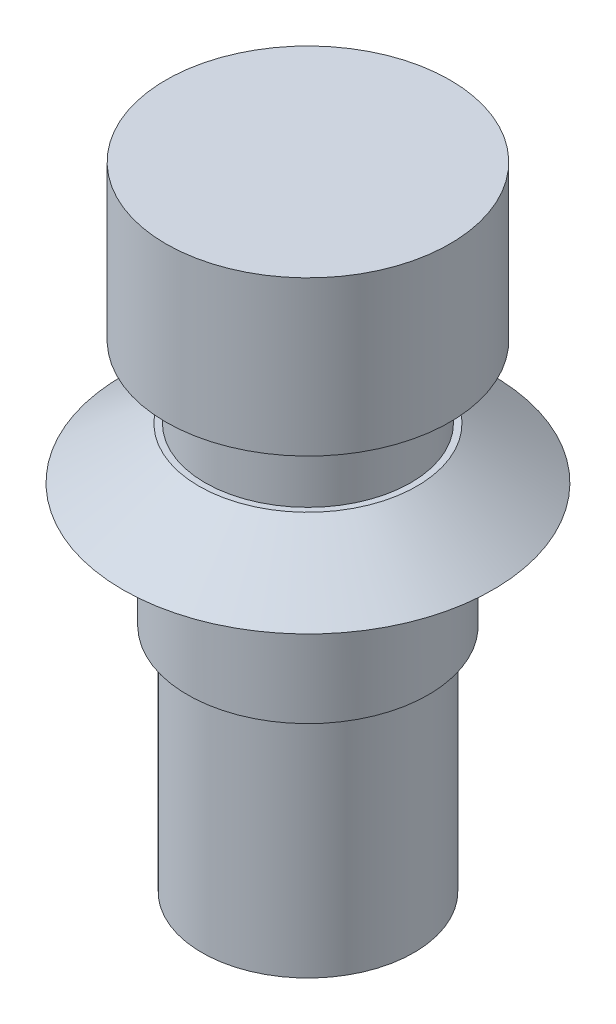
from build123d import *

# Parameters (mm, degrees)
SKETCH1_R           = 5.85
BOSS_EXTRUDE1_DEPTH = 17.2
SKETCH2_R           = 9
BOSS_EXTRUDE2_DEPTH = 2.5
BOSS_EXTRUDE2_TAPER = 56
SKETCH3_R           = 5
BOSS_EXTRUDE3_DEPTH = 3.5
SKETCH4_R           = 6.9
BOSS_EXTRUDE4_DEPTH = 7.5
SKETCH5_OUTSIDE_W   = 27.976
SKETCH5_OUTSIDE_H   = 27.976
SKETCH5_OUTSIDE_R   = 5.15
CUT_EXTRUDE1_DEPTH  = 11.2


with BuildPart() as part:
    # Sketch1 → Boss-Extrude1 (new body)
    with BuildSketch(Plane(origin=(0, 0, 0), x_dir=(1, 0, 0), z_dir=(0, 1, 0))):
        with Locations(Location((0, 0, 0), (0, 0, 270))):  # turned: the seam where the file's is
            Circle(SKETCH1_R)
    extrude(amount=BOSS_EXTRUDE1_DEPTH)

    # Sketch2 → Boss-Extrude2 (add)
    with BuildSketch(Plane(origin=(0, 17.2, 0), x_dir=(1, 0, 0), z_dir=(0, 1, 0))):
        Circle(SKETCH2_R)
    extrude(amount=BOSS_EXTRUDE2_DEPTH, taper=BOSS_EXTRUDE2_TAPER)

    # Sketch3 → Boss-Extrude3 (add)
    with BuildSketch(Plane(origin=(0, 19.7, 0), x_dir=(1, 0, 0), z_dir=(0, 1, 0))):
        with Locations(Location((0, 0, 0), (0, 0, 270))):  # turned: the seam where the file's is
            Circle(SKETCH3_R)
    extrude(amount=BOSS_EXTRUDE3_DEPTH)

    # Sketch4 → Boss-Extrude4 (add)
    with BuildSketch(Plane(origin=(0, 23.2, 0), x_dir=(1, 0, 0), z_dir=(0, 1, 0))):
        with Locations(Location((0, 0, 0), (0, 0, 270))):  # turned: the seam where the file's is
            Circle(SKETCH4_R)
    extrude(amount=BOSS_EXTRUDE4_DEPTH)

    # Sketch5 outside → Cut-Extrude1 (cut)
    with BuildSketch(Plane.XZ):
        Rectangle(SKETCH5_OUTSIDE_W, SKETCH5_OUTSIDE_H)
        with Locations(Location((0, 0, 0), (0, 0, 270))):  # turned: the seam where the file's is
            Circle(SKETCH5_OUTSIDE_R, mode=Mode.SUBTRACT)
    extrude(amount=-CUT_EXTRUDE1_DEPTH, mode=Mode.SUBTRACT)


solid = part.part
